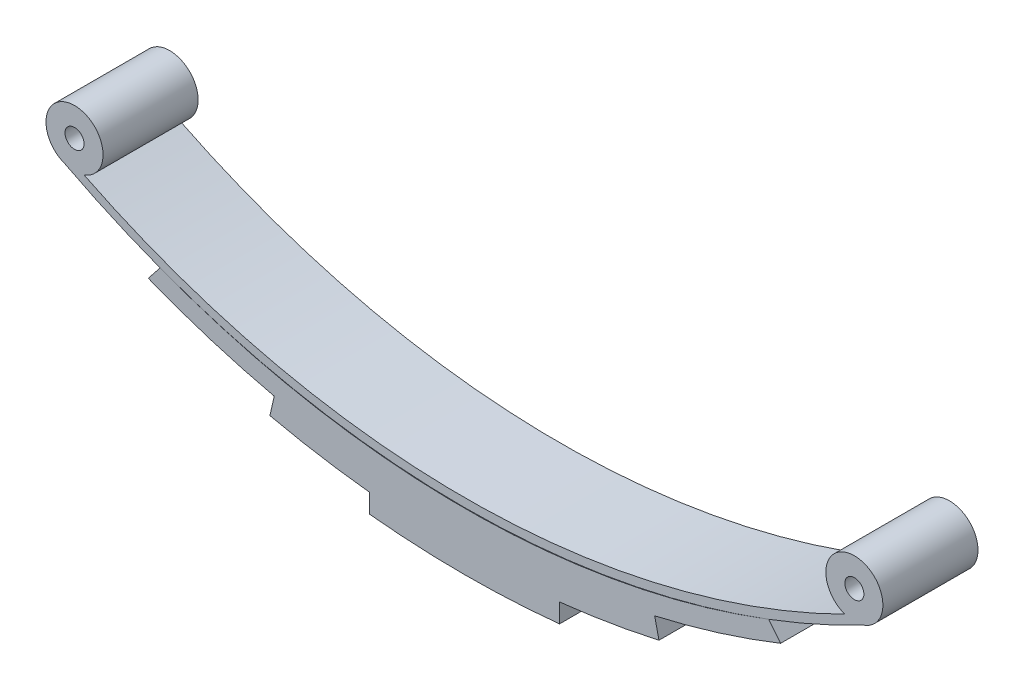
from build123d import *

# Parameters (mm, degrees)
SKETCH1_R            = 1
BOSS_EXTRUDE1_DEPTH  = 10
BOSS_EXTRUDE3_DEPTH  = 10
BOSS_EXTRUDE5_DEPTH  = 10
BOSS_EXTRUDE12_DEPTH = 10


with BuildPart() as part:
    # Sketch1 → Boss-Extrude1 (new body)
    with BuildSketch(Plane.XY):
        with BuildLine():
            ThreePointArc((-40, 0), (0, -9.377422517), (40, 0))
            ThreePointArc((40, 0), (41, 5.828427125), (42, 0))
            ThreePointArc((42, 0), (0, -10.283967936), (-42, 0))
            ThreePointArc((-42, 0), (-41, 5.828427125), (-40, 0))
        make_face()
        with Locations((-41, 2.828427125)):
            Circle(SKETCH1_R, mode=Mode.SUBTRACT)
        with Locations((41, 2.828427125)):
            Circle(SKETCH1_R, mode=Mode.SUBTRACT)
    extrude(amount=BOSS_EXTRUDE1_DEPTH)


with BuildPart() as body_2:
    # Sketch2 → Boss-Extrude3 (new body)
    with BuildSketch(Plane.XY):
        with BuildLine():
            Line((-33.245929305, -6.030112035), (-32, -4.465612062))
            ThreePointArc((-32, -4.465612062), (0, -10.346648682), (32, -4.465612062))
            Line((32, -4.465612062), (33.245929305, -6.030112035))
            ThreePointArc((33.245929305, -6.030112035), (0, -12.395740006), (-33.245929305, -6.030112035))
        make_face()
    extrude(amount=BOSS_EXTRUDE3_DEPTH)

    # Sketch3 → Boss-Extrude5 (add)
    with BuildSketch(Plane.XY):
        with BuildLine():
            Line((-20, -10.14538388), (-20.455842306, -12.14538388))
            ThreePointArc((-20.455842306, -12.14538388), (0, -14.422958232), (20.455842306, -12.14538388))
            Line((20.455842306, -12.14538388), (20, -10.14538388))
            ThreePointArc((20, -10.14538388), (0, -12.395740006), (-20, -10.14538388))
        make_face()
    extrude(amount=BOSS_EXTRUDE5_DEPTH)

    # Sketch4 → Boss-Extrude12 (add, through all)
    with BuildSketch(Plane.XY):
        with BuildLine():
            Line((-10, -13.883760737), (-10, -15.883760737))
            ThreePointArc((-10, -15.883760737), (0, -16.395299882), (10, -15.883760737))
            Line((10, -15.883760737), (10, -13.883760737))
            ThreePointArc((10, -13.883760737), (0, -14.422958232), (-10, -13.883760737))
        make_face()
    extrude(amount=BOSS_EXTRUDE12_DEPTH)


solid = Compound([part.part, body_2.part])
